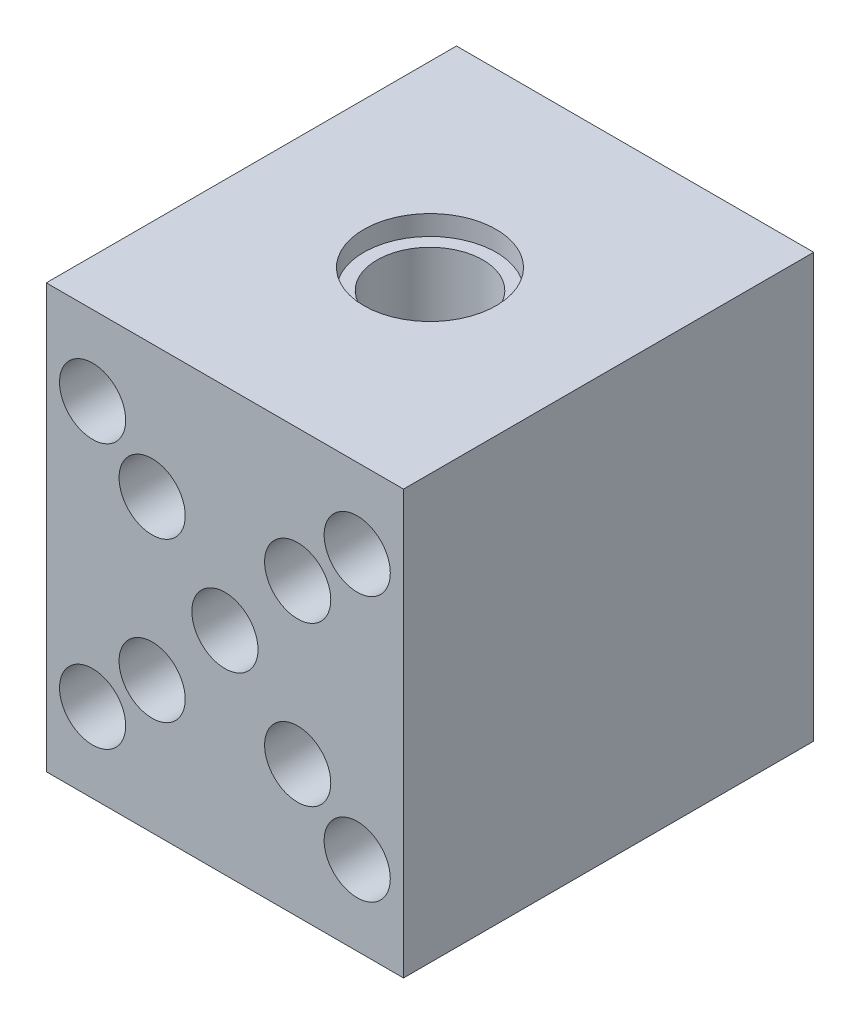
from build123d import *

# Parameters (mm, degrees)
SCHIZZO1_W                   = 27
SCHIZZO1_H                   = 32
ESTRUSIONE_ESTRUSIONE1_DEPTH = 31
SCHIZZO2_R                   = 1.5
TAGLIO_ESTRUSIONE1_DEPTH     = 32
SCHIZZO3_R                   = 4
TAGLIO_ESTRUSIONE2_DEPTH     = 33
SCHIZZO4_R                   = 5
TAGLIO_ESTRUSIONE5_DEPTH     = 1.5
SCHIZZO5_R                   = 5
TAGLIO_ESTRUSIONE6_DEPTH     = 1.5
SCHIZZO6_R                   = 2.5
TAGLIO_ESTRUSIONE7_DEPTH     = 15
SCHIZZO7_R                   = 2.5
TAGLIO_ESTRUSIONE8_DEPTH     = 10


with BuildPart() as part:
    # Schizzo1 → Estrusione-Estrusione1 (new body)
    with BuildSketch(Plane.XY):
        Rectangle(SCHIZZO1_W, SCHIZZO1_H)
    extrude(amount=ESTRUSIONE_ESTRUSIONE1_DEPTH)

    # Schizzo2 → Taglio-Estrusione1 (cut, through all)
    with BuildSketch(Plane(origin=(0, 0, 0), x_dir=(-1, 0, 0), z_dir=(0, 0, -1))):
        with Locations((-10, 10)):
            Circle(SCHIZZO2_R)
        with Locations((10, 10)):
            Circle(SCHIZZO2_R)
        with Locations((10, -10)):
            Circle(SCHIZZO2_R)
        with Locations((-10, -10)):
            Circle(SCHIZZO2_R)
    extrude(amount=-TAGLIO_ESTRUSIONE1_DEPTH, mode=Mode.SUBTRACT)

    # Schizzo3 → Taglio-Estrusione2 (cut, through all)
    with BuildSketch(Plane(origin=(0, 16, 0), x_dir=(1, 0, 0), z_dir=(0, 1, 0))):
        with Locations((0, -15.5)):
            Circle(SCHIZZO3_R)
    extrude(amount=-TAGLIO_ESTRUSIONE2_DEPTH, mode=Mode.SUBTRACT)

    # Schizzo4 → Taglio-Estrusione5 (cut)
    with BuildSketch(Plane(origin=(0, 16, 0), x_dir=(1, 0, 0), z_dir=(0, 1, 0))):
        with Locations((0, -15.5)):
            Circle(SCHIZZO4_R)
    extrude(amount=-TAGLIO_ESTRUSIONE5_DEPTH, mode=Mode.SUBTRACT)

    # Schizzo5 → Taglio-Estrusione6 (cut)
    with BuildSketch(Plane.XZ.offset(16)):
        with Locations((0, 15.5)):
            Circle(SCHIZZO5_R)
    extrude(amount=-TAGLIO_ESTRUSIONE6_DEPTH, mode=Mode.SUBTRACT)

    # Schizzo6 → Taglio-Estrusione7 (cut)
    with BuildSketch(Plane.XY.offset(31)):
        with Locations((-10, 10)):
            Circle(SCHIZZO6_R)
        with Locations((10, 10)):
            Circle(SCHIZZO6_R)
        with Locations((10, -10)):
            Circle(SCHIZZO6_R)
        with Locations((-10, -10)):
            Circle(SCHIZZO6_R)
    extrude(amount=-TAGLIO_ESTRUSIONE7_DEPTH, mode=Mode.SUBTRACT)

    # Schizzo7 → Taglio-Estrusione8 (cut)
    with BuildSketch(Plane.XY.offset(31)):
        with Locations((-5.5, 6)):
            Circle(SCHIZZO7_R)
        with Locations((5.5, 6)):
            Circle(SCHIZZO7_R)
        Circle(SCHIZZO7_R)
        with Locations((5.5, -6)):
            Circle(SCHIZZO7_R)
        with Locations((-5.5, -6)):
            Circle(SCHIZZO7_R)
    extrude(amount=-TAGLIO_ESTRUSIONE8_DEPTH, mode=Mode.SUBTRACT)


solid = part.part
